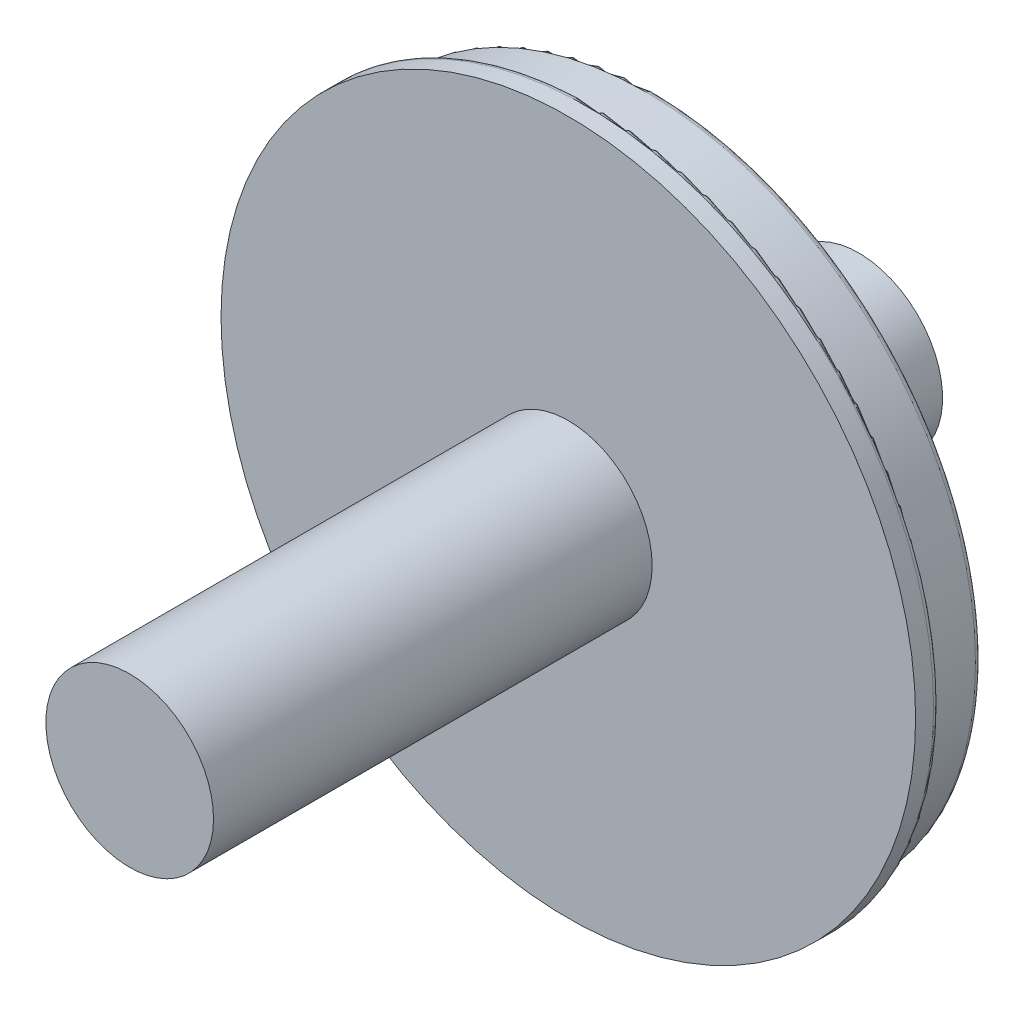
from build123d import *

# Parameters (mm, degrees)
SCHIZZO4_R                   = 580
ESTRUSIONE_ESTRUSIONE1_DEPTH = 40
SCHIZZO5_R                   = 550
ESTRUSIONE_ESTRUSIONE2_DEPTH = 100
RACCORDO4_R                  = 10
RACCORDO3_R                  = 10
SCHIZZO6_R                   = 140
ESTRUSIONE_ESTRUSIONE3_DEPTH = 732.5
SCHIZZO8_R                   = 140
ESTRUSIONE_ESTRUSIONE4_DEPTH = 345
TAGLIO_ESTRUSIONE2_DEPTH     = 20


with BuildPart() as part:
    # Schizzo4 → Estrusione-Estrusione1 (new body)
    with BuildSketch(Plane.XY):
        Circle(SCHIZZO4_R)
    extrude(amount=ESTRUSIONE_ESTRUSIONE1_DEPTH)

    # Schizzo5 → Estrusione-Estrusione2 (add)
    with BuildSketch(Plane(origin=(0, 0, 0), x_dir=(-1, 0, 0), z_dir=(0, 0, -1))):
        Circle(SCHIZZO5_R)
    extrude(amount=ESTRUSIONE_ESTRUSIONE2_DEPTH)

    # Raccordo4
    raccordo4_edges = [part.edges().sort_by_distance(p)[0] for p in [
        (-580, 0, 0),
        (550, 0, 0),
    ]]
    fillet(raccordo4_edges, radius=RACCORDO4_R)

    # Raccordo3
    raccordo3_edges = [part.edges().sort_by_distance(p)[0] for p in [
        (550, 0, -100),
    ]]
    fillet(raccordo3_edges, radius=RACCORDO3_R)

    # Schizzo6 → Estrusione-Estrusione3 (add)
    with BuildSketch(Plane.XY.offset(40)):
        Circle(SCHIZZO6_R)
    extrude(amount=ESTRUSIONE_ESTRUSIONE3_DEPTH)

    # Schizzo8 → Estrusione-Estrusione4 (add)
    with BuildSketch(Plane(origin=(0, 0, -100), x_dir=(-1, 0, 0), z_dir=(0, 0, -1))):
        with Locations(Location((0, 0, 0), (0, 0, 180))):
            Circle(SCHIZZO8_R)
    extrude(amount=ESTRUSIONE_ESTRUSIONE4_DEPTH)

    # Schizzo3D1 → Taglio-Estrusione2 (cut)
    with BuildSketch(Plane(origin=(-490, 0, -100), x_dir=(0.9999994625775602, -0.0010367471199618189, 0), z_dir=(0, 0, 1))):
        with BuildLine():
            add(Edge.make_bspline(
                [(0, 0), (-0.012889025, 12.324775606), (0.892505318, 36.969516199), (5.031720953, 73.734080783), (11.930813088, 110.08041258), (21.551001502, 145.804732388), (36.55920901, 188.443583214), (59.310799707, 236.88933115), (92.353568708, 289.032909391), (126.446679246, 330.291660739), (158.595093697, 362.068978642), (186.79160637, 386.021723619), (216.712322863, 407.779392219), (248.189766305, 427.220231533), (288.329062139, 448.008823547), (338.086656252, 467.724996678), (397.879393929, 483.086996482), (459.13037451, 490.830349457), (520.867876847, 490.830323821), (582.11818298, 483.087577434), (641.913744877, 467.724202681), (699.310395142, 444.982855454), (753.401739088, 415.222640068), (803.333606643, 378.913514395), (848.317503701, 336.628848258), (887.643073475, 289.036374583), (920.689311341, 236.887643526), (946.934372059, 181.006154856), (965.963810233, 122.274353668), (977.477125024, 61.619695392), (981.29250545, 0), (977.349701439, -61.611673282), (965.710975256, -122.242391905), (946.560118305, -180.934713942), (920.199548763, -236.761807382), (887.045536191, -288.842086137), (847.621627278, -336.353131282), (802.550381275, -378.544678935), (752.543527929, -414.750465128), (698.39076934, -444.39875755), (640.947156342, -467.021344687), (581.120157602, -482.2610762), (519.85319651, -489.876955394), (458.11871347, -489.749987888), (405.034017684, -482.926445703), (361.005254012, -472.689424768), (325.702985951, -461.620298825), (291.337369241, -447.921765869), (258.100752256, -431.67047026), (219.103056071, -408.812251082), (175.880382447, -377.246047708), (130.988657581, -334.872583225), (96.982463241, -293.542168627), (71.913392038, -255.927535867), (53.772486211, -223.683394901), (38.115010499, -190.16489219), (25.028466811, -155.559863125), (12.36477641, -112.517739342), (2.563418858, -60.5980959), (0.021119176, -20.194630929), (0, 0)],
                knots=[0, 0, 0, 0, 0.012011675, 0.024023503, 0.036035247, 0.04804697, 0.060058723, 0.080069863, 0.100081004, 0.120092144, 0.132103892, 0.144115629, 0.156127383, 0.168139121, 0.180150868, 0.200162009, 0.220173149, 0.240184289, 0.26019543, 0.28020657, 0.300217711, 0.320228851, 0.340239992, 0.360251132, 0.380262272, 0.400273413, 0.420284553, 0.440295694, 0.460306834, 0.480317974, 0.500329115, 0.520340255, 0.540351396, 0.560362536, 0.580373677, 0.600384817, 0.620395957, 0.640407098, 0.660418238, 0.680429379, 0.700440519, 0.72045166, 0.7404628, 0.76047394, 0.780485081, 0.792496828, 0.804508566, 0.81652032, 0.828532057, 0.840543805, 0.860554945, 0.880566085, 0.900577226, 0.912588972, 0.924600713, 0.936612469, 0.948624184, 0.96063595, 0.980318397, 1, 1, 1, 1], degree=3))
        make_face()
    extrude(amount=TAGLIO_ESTRUSIONE2_DEPTH, mode=Mode.SUBTRACT)


with BuildPart() as taglio_estrusione2_piece_1:
    # of the separate pieces the step leaves, piece 1, a body of its own (taglio_estrusione2_pieces)
    add(part.part.solids().sort_by_distance((-550, 0, -90))[0])


with BuildPart() as taglio_estrusione2_piece_2:
    # of the separate pieces the step leaves, piece 2, a body of its own (taglio_estrusione2_pieces)
    add(part.part.solids().sort_by_distance((140, 0, -100))[0])


solid = Compound([taglio_estrusione2_piece_1.part, taglio_estrusione2_piece_2.part])
